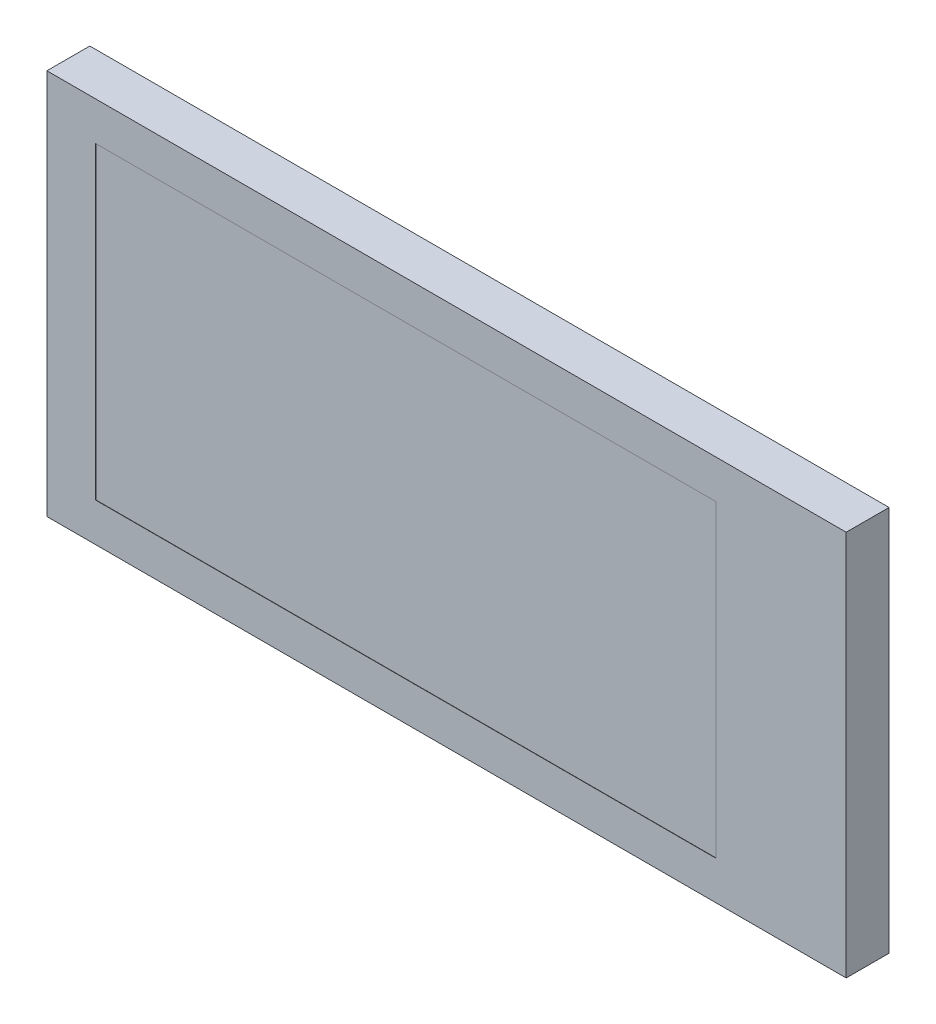
from build123d import *

# Parameters (mm, degrees)
SKETCH_1_W      = 27.95
SKETCH_1_H      = 13.5
SKETCH_1_W_2    = 21.7
SKETCH_1_H_2    = 10.8
EXTRUDE_1_DEPTH = 1.5
SKETCH_1_2_W    = 21.7
SKETCH_1_2_H    = 10.8
EXTRUDE_2_DEPTH = 1.49


with BuildPart() as part:
    # 草图1 → 凸台-拉伸1 (new body)
    with BuildSketch(Plane.XY):
        with Locations((13.975, 6.75)):
            Rectangle(SKETCH_1_W, SKETCH_1_H)
        with Locations((12.55, 6.75)):
            Rectangle(SKETCH_1_W_2, SKETCH_1_H_2, mode=Mode.SUBTRACT)
    extrude(amount=EXTRUDE_1_DEPTH)

    # 草图1<2> → 凸台-拉伸2 (add)
    with BuildSketch(Plane.XY):
        with Locations((12.55, 6.75)):
            Rectangle(SKETCH_1_2_W, SKETCH_1_2_H)
    extrude(amount=EXTRUDE_2_DEPTH)


solid = part.part
